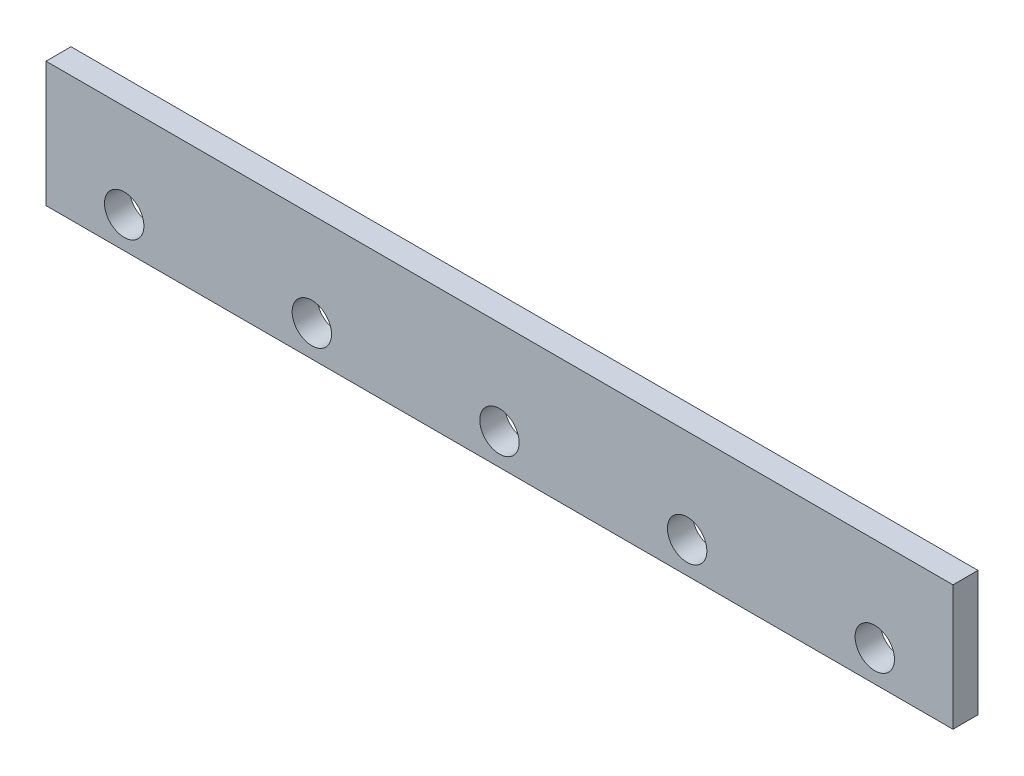
from build123d import *

# Parameters (mm, degrees)
SKETCH1_W           = 580
SKETCH1_H           = 80
BOSS_EXTRUDE1_DEPTH = 16
SKETCH2_R           = 12.6
CUT_EXTRUDE1_DEPTH  = 16
SKETCH4_R           = 12.6
CUT_EXTRUDE2_DEPTH  = 16
SKETCH5_R           = 12.6
CUT_EXTRUDE3_DEPTH  = 16


with BuildPart() as part:
    # Sketch1 → Boss-Extrude1 (new body)
    with BuildSketch(Plane.XY):
        with Locations((290, 40)):
            Rectangle(SKETCH1_W, SKETCH1_H)
    extrude(amount=BOSS_EXTRUDE1_DEPTH)

    # Sketch2 → Cut-Extrude1 (cut)
    with BuildSketch(Plane.XY.offset(16)):
        with Locations((50, 20)):
            Circle(SKETCH2_R)
    extrude(amount=-CUT_EXTRUDE1_DEPTH, mode=Mode.SUBTRACT)

    # Sketch4 → Cut-Extrude2 (cut)
    with BuildSketch(Plane.XY.offset(16)):
        with Locations((170, 20)):
            Circle(SKETCH4_R)
    extrude(amount=-CUT_EXTRUDE2_DEPTH, mode=Mode.SUBTRACT)

    # Sketch5 → Cut-Extrude3 (cut)
    with BuildSketch(Plane.XY.offset(16)):
        with Locations((290, 20)):
            Circle(SKETCH5_R)
        with Locations((410, 20)):
            Circle(SKETCH5_R)
        with Locations((530, 20)):
            Circle(SKETCH5_R)
    extrude(amount=-CUT_EXTRUDE3_DEPTH, mode=Mode.SUBTRACT)


solid = part.part
